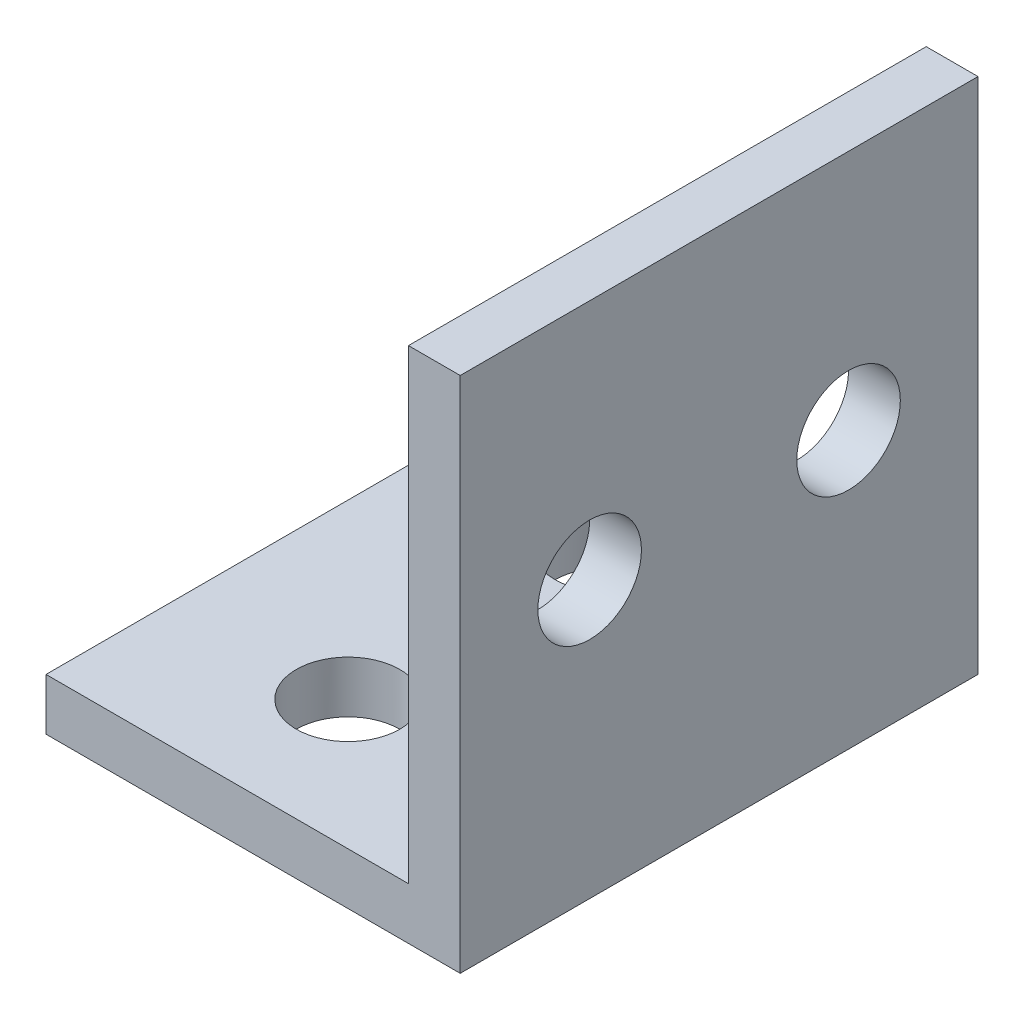
from build123d import *

# Parameters (mm, degrees)
AUFSATZ_LINEAR_AUSTRAGEN1_DEPTH      = 15
AUFSATZ_LINEAR_AUSTRAGEN1_DEPTH_BACK = 15
SKIZZE6_R                            = 3
SCHNITT_LINEAR_AUSTRAGEN1_DEPTH      = 14
SKIZZE8_R                            = 3
SCHNITT_LINEAR_AUSTRAGEN2_DEPTH      = 24


with BuildPart() as part:
    # Skizze3 → Aufsatz-Linear austragen1 (new body, two sides)
    with BuildSketch(Plane.XY) as aufsatz_linear_austragen1_sk:
        Polygon((-14, 24), (-35, 24), (-35, 21), (-11, 21), (-11, 51), (-14, 51), align=None)
    extrude(amount=AUFSATZ_LINEAR_AUSTRAGEN1_DEPTH)
    extrude(aufsatz_linear_austragen1_sk.sketch, amount=-AUFSATZ_LINEAR_AUSTRAGEN1_DEPTH_BACK)

    # Skizze6 → Schnitt-Linear austragen1 (cut)
    with BuildSketch(Plane(origin=(0, 0, 0), x_dir=(0, 0, -1), z_dir=(1, 0, 0))):
        with Locations((7.5, 37)):
            Circle(SKIZZE6_R)
        with Locations((-7.5, 37)):
            Circle(SKIZZE6_R)
    extrude(amount=-SCHNITT_LINEAR_AUSTRAGEN1_DEPTH, mode=Mode.SUBTRACT)

    # Skizze8 → Schnitt-Linear austragen2 (cut)
    with BuildSketch(Plane(origin=(0, 0, 0), x_dir=(1, 0, 0), z_dir=(0, 1, 0))):
        with Locations((-25, 7.5)):
            Circle(SKIZZE8_R)
        with Locations((-25, -7.5)):
            Circle(SKIZZE8_R)
    extrude(amount=SCHNITT_LINEAR_AUSTRAGEN2_DEPTH, mode=Mode.SUBTRACT)


solid = part.part
